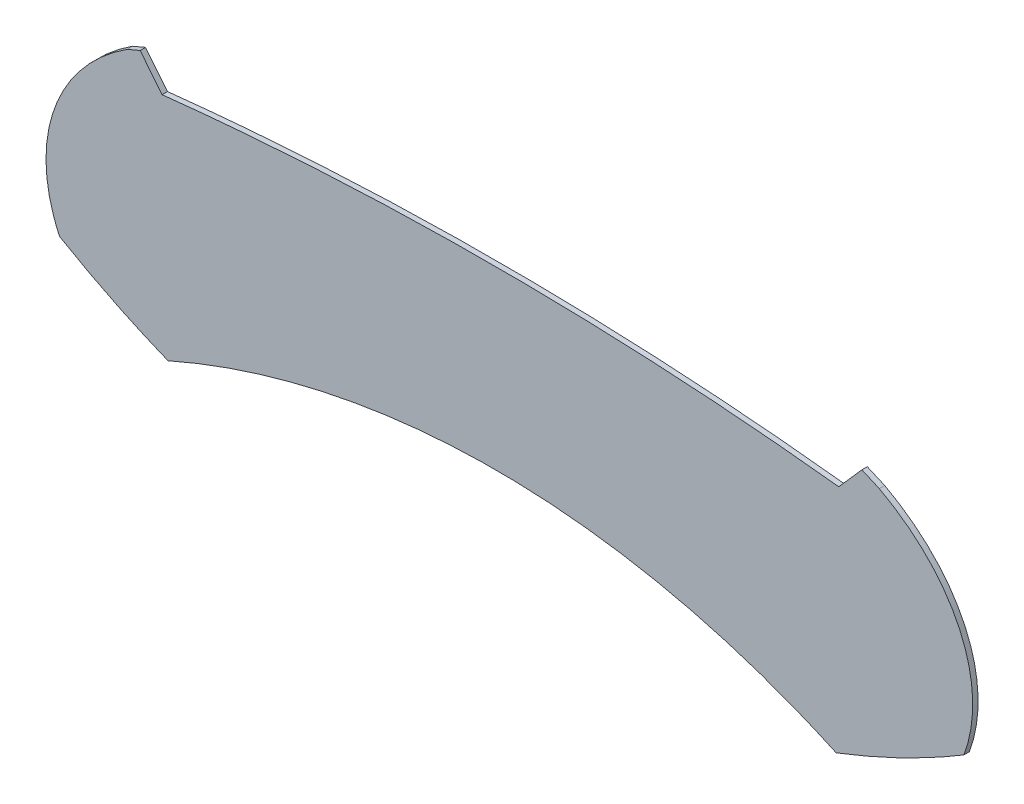
from build123d import *

# Parameters (mm, degrees)
SALIENTE_EXTRUIR1_DEPTH = 0.1


with BuildPart() as part:
    # Model → Saliente-Extruir1 (new body)
    with BuildSketch(Plane.XY):
        with BuildLine():
            add(Edge.make_bspline(
                [(54.570583832, 30.809459397), (54.367516513, 31.062309536), (54.164449193, 31.315159675)],
                knots=[5.050094229, 5.050094229, 5.050094229, 6.050094229, 6.050094229, 6.050094229], degree=2, weights=[1, 1, 1]))
            add(Edge.make_bspline(
                [(54.164449193, 31.315159675), (54.043855277, 31.265315881), (53.924453385, 31.213668077)],
                knots=[0, 0, 0, 0.018791538, 0.018791538, 0.018791538], degree=2, weights=[1, 0.99995586, 1]))
            add(Edge.make_bspline(
                [(53.924453385, 31.213668077), (51.666875483, 29.761650164), (52.670517155, 27.587817765)],
                knots=[0.018791538, 0.018791538, 0.018791538, 1.266242996, 1.266242996, 1.266242996], degree=2, weights=[1, 0.811708033, 1]))
            add(Edge.make_bspline(
                [(52.670517155, 27.587817765), (53.62304942, 27.025028989), (54.680131861, 26.59810553)],
                knots=[1.266242996, 1.266242996, 1.266242996, 1.434861453, 1.434861453, 1.434861453], degree=2, weights=[1, 0.996448082, 1]))
            add(Edge.make_bspline(
                [(54.680131861, 26.59810553), (60.888771996, 29.345532705), (67.05144986, 26.496503052)],
                knots=[1.434861453, 1.434861453, 1.434861453, 2.28451346, 2.28451346, 2.28451346], degree=2, weights=[1, 0.911110461, 1]))
            add(Edge.make_bspline(
                [(67.05144986, 26.496503052), (68.305506812, 26.977392792), (69.416942944, 27.646101117)],
                knots=[2.28451346, 2.28451346, 2.28451346, 2.482363868, 2.482363868, 2.482363868], degree=2, weights=[1, 0.995110891, 1]))
            add(Edge.make_bspline(
                [(69.416942944, 27.646101117), (70.236120065, 29.850566621), (67.849759205, 31.132955517)],
                knots=[2.482363868, 2.482363868, 2.482363868, 3.750620329, 3.750620329, 3.750620329], degree=2, weights=[1, 0.805588504, 1]))
            add(Edge.make_bspline(
                [(67.849759205, 31.132955517), (67.689744673, 31.204586758), (67.527509068, 31.272945811)],
                knots=[3.750620329, 3.750620329, 3.750620329, 3.77600443, 3.77600443, 3.77600443], degree=2, weights=[1, 0.999919457, 1]))
            add(Edge.make_bspline(
                [(67.527509068, 31.272945811), (67.313211267, 31.030007557), (67.098913467, 30.787069303)],
                knots=[3.77600443, 3.77600443, 3.77600443, 4.77600443, 4.77600443, 4.77600443], degree=2, weights=[1, 1, 1]))
            add(Edge.make_bspline(
                [(67.098913467, 30.787069303), (60.836678527, 31.489373894), (54.570583832, 30.809459397)],
                knots=[4.77600443, 4.77600443, 4.77600443, 5.050094229, 5.050094229, 5.050094229], degree=2, weights=[1, 0.990624036, 1]))
        make_face()
    extrude(amount=SALIENTE_EXTRUIR1_DEPTH)


solid = part.part
